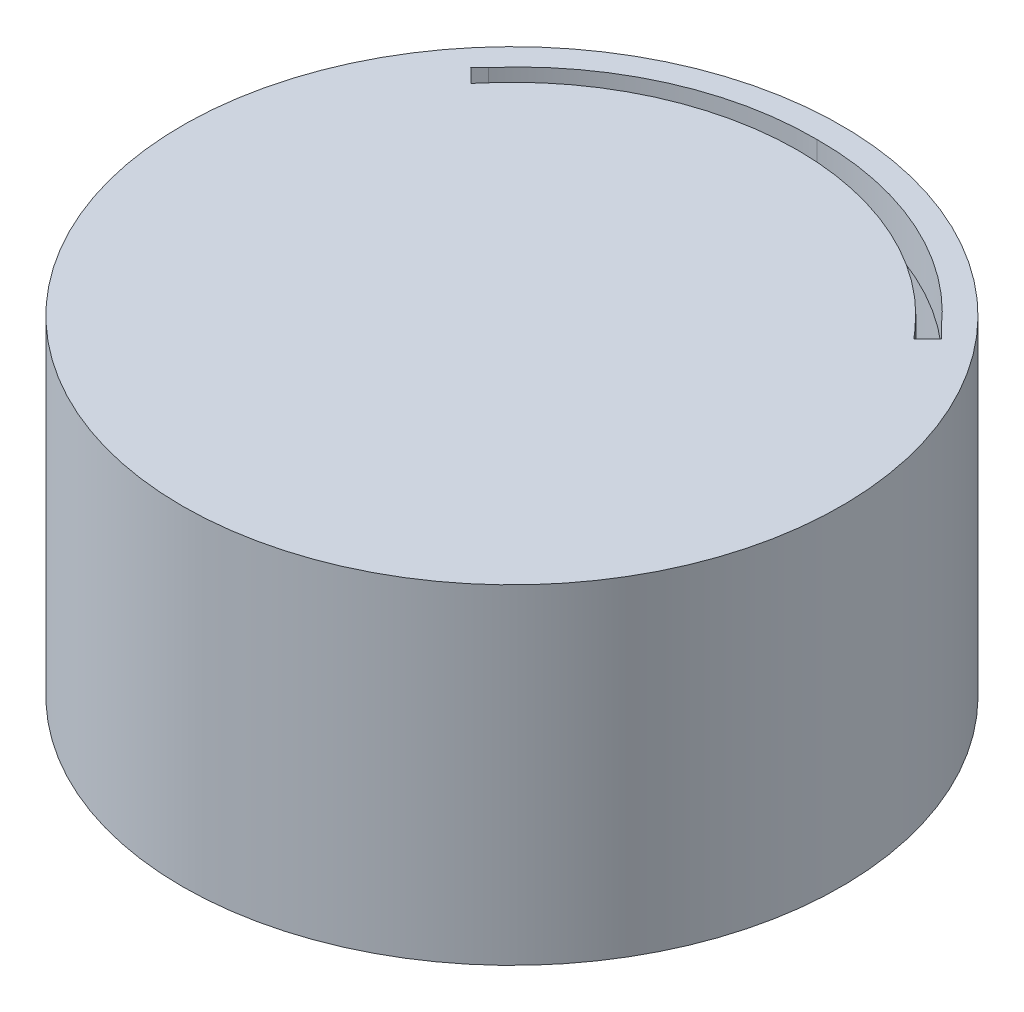
from build123d import *

# Parameters (mm, degrees)
SKETCH_1_R          = 30
EXTRUDE_1_DEPTH     = 30
SKETCH_2_R          = 29
CUT_EXTRUDE_1_DEPTH = 26
CUT_EXTRUDE_3_DEPTH = 74


with BuildPart() as part:
    # 草圖1 → 填料-伸長1 (new body)
    with BuildSketch(Plane(origin=(0, 0, 0), x_dir=(1, 0, 0), z_dir=(0, 1, 0))):
        Circle(SKETCH_1_R)
    extrude(amount=EXTRUDE_1_DEPTH)

    # 草圖2 → 除料-伸長1 (cut)
    with BuildSketch(Plane(origin=(0, 0, 0), x_dir=(1, 0, 0), z_dir=(0, 1, 0))):
        Circle(SKETCH_2_R)
    extrude(amount=CUT_EXTRUDE_1_DEPTH, mode=Mode.SUBTRACT)

    # 草圖4 → 除料-伸長3 (cut)
    with BuildSketch(Plane(origin=(0, 0, 0), x_dir=(1, 0, 0), z_dir=(0, 1, 0))):
        with BuildLine():
            Line((-20.622074934, 18.510350175), (-21.441043067, 17.691382042))
            Line((-21.441043067, 17.691382042), (-20.175275746, 16.455577197))
            Line((-20.175275746, 16.455577197), (-19.55132785, 17.175583262))
            ThreePointArc((-19.55132785, 17.175583262), (-10.748837833, 23.729884815), (-0.025402307, 26.064543216))
            ThreePointArc((-0.025402307, 26.064543216), (10.698033219, 23.729884815), (19.500523236, 17.175583262))
            Line((19.500523236, 17.175583262), (20.124471132, 16.455577197))
            Line((20.124471132, 16.455577197), (21.390238453, 17.691382042))
            Line((21.390238453, 17.691382042), (20.57127032, 18.510350175))
            ThreePointArc((20.57127032, 18.510350175), (11.290375881, 25.406586919), (-0.025402307, 27.782770163))
            ThreePointArc((-0.025402307, 27.782770163), (-11.341180495, 25.406586919), (-20.622074934, 18.510350175))
        make_face()
    extrude(amount=CUT_EXTRUDE_3_DEPTH, mode=Mode.SUBTRACT)


solid = part.part
